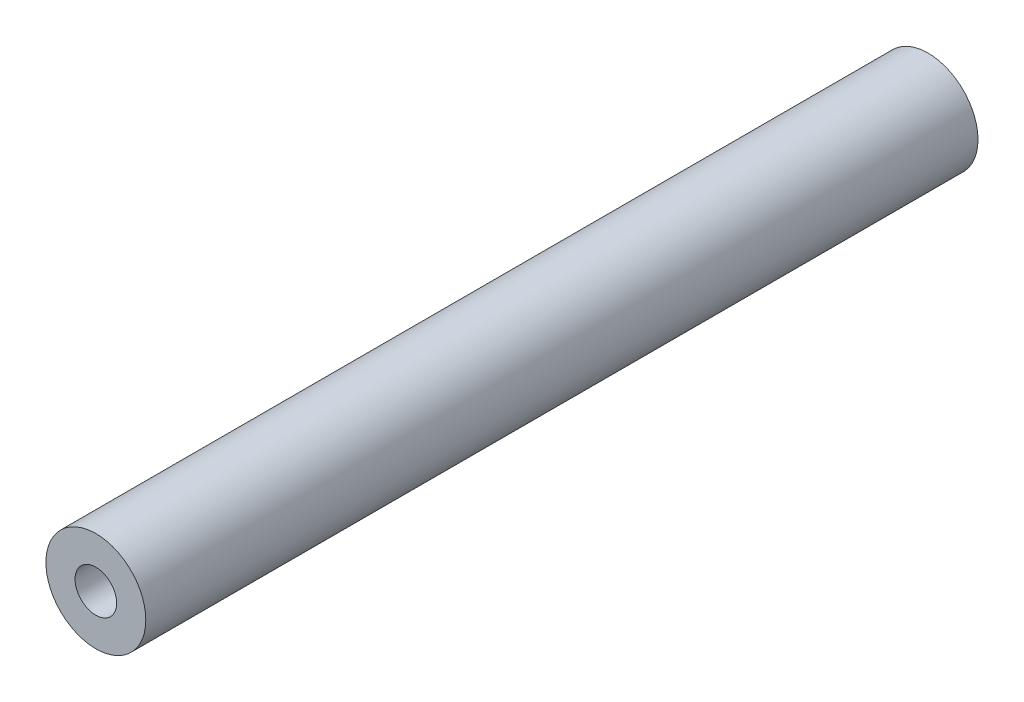
from build123d import *

# Parameters (mm, degrees)
SKETCH_1_R             = 6
EXTRUDE_1_DEPTH        = 100
HOLE_WIZARD_M6_1_D     = 5
HOLE_WIZARD_M6_1_DEPTH = 15
HOLE_WIZARD_M6_1_TIP   = 1.502151548
HOLE_WIZARD_M6_2_D     = 5
HOLE_WIZARD_M6_2_DEPTH = 15
HOLE_WIZARD_M6_2_TIP   = 1.502151548


with BuildPart() as part:
    # 草图1 → 凸台-拉伸1 (new body)
    with BuildSketch(Plane.XY):
        Circle(SKETCH_1_R)
    extrude(amount=EXTRUDE_1_DEPTH)

    # M6 螺纹孔1
    with Locations(Plane(origin=(0, 0, 0), x_dir=(-1, 0, 0), z_dir=(0, 0, -1))):
        with Locations((0, 0)):
            Hole(HOLE_WIZARD_M6_1_D / 2, depth=HOLE_WIZARD_M6_1_DEPTH)
            with Locations((0, 0, -(HOLE_WIZARD_M6_1_DEPTH + HOLE_WIZARD_M6_1_TIP / 2))):  # 118° drill point
                Cone(0, HOLE_WIZARD_M6_1_D / 2, HOLE_WIZARD_M6_1_TIP, mode=Mode.SUBTRACT)

    # M6 螺纹孔2
    with Locations(Plane.XY.offset(100)):
        with Locations((0, 0)):
            Hole(HOLE_WIZARD_M6_2_D / 2, depth=HOLE_WIZARD_M6_2_DEPTH)
            with Locations((0, 0, -(HOLE_WIZARD_M6_2_DEPTH + HOLE_WIZARD_M6_2_TIP / 2))):  # 118° drill point
                Cone(0, HOLE_WIZARD_M6_2_D / 2, HOLE_WIZARD_M6_2_TIP, mode=Mode.SUBTRACT)


solid = part.part
